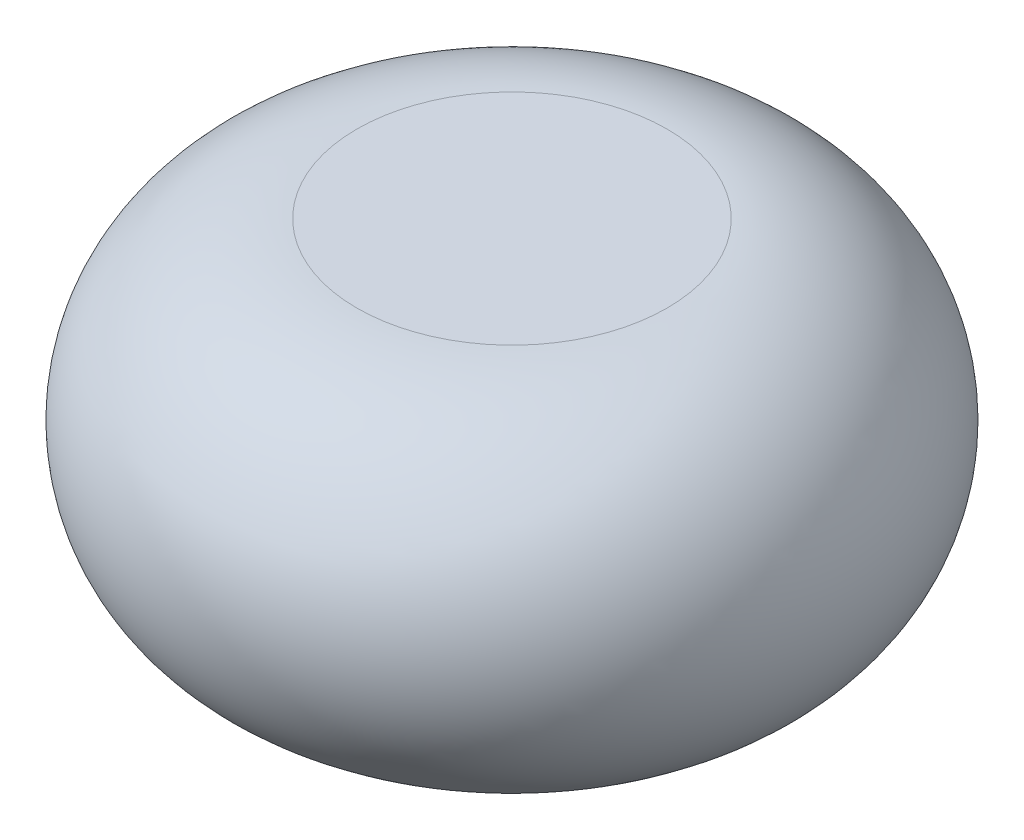
from build123d import *


with BuildPart() as part:
    # Sketch1 → Revolve2 (revolve)
    with BuildSketch(Plane.XY):
        with BuildLine():
            Line((0, 625), (0, -500))
            Line((0, -500), (500, -500))
            ThreePointArc((500, -500), (1062.5, 62.5), (500, 625))
            Line((500, 625), (0, 625))
        make_face()
    revolve(axis=Axis((0, 550, 0), (0, -1, 0)))


solid = part.part
